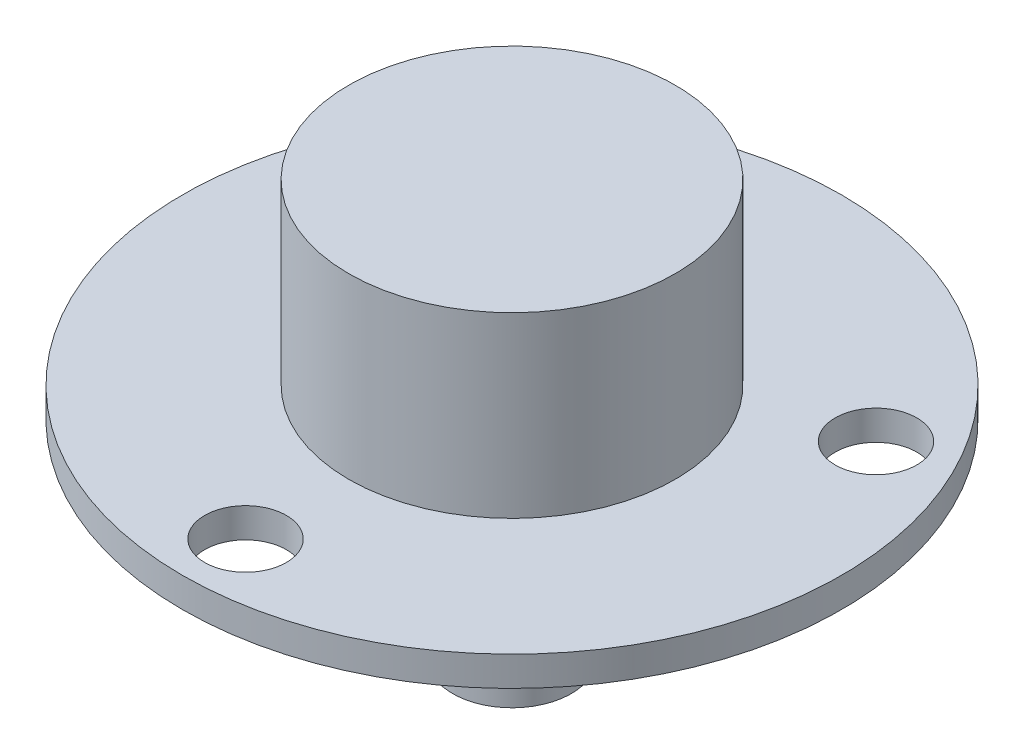
from build123d import *

# Parameters (mm, degrees)
SKETCH1_R           = 22.2
BOSS_EXTRUDE1_DEPTH = 2
SKETCH2_R           = 11
BOSS_EXTRUDE2_DEPTH = 12
BOSS_EXTRUDE3_START = -7
SKETCH2_2_R         = 11
BOSS_EXTRUDE3_DEPTH = 7
SKETCH3_R           = 4
BOSS_EXTRUDE4_DEPTH = 9
SKETCH4_R           = 2.75
CUT_EXTRUDE1_DEPTH  = 3.1


with BuildPart() as part:
    # Sketch1 → Boss-Extrude1 (new body)
    with BuildSketch(Plane(origin=(0, 0, 0), x_dir=(1, 0, 0), z_dir=(0, 1, 0))):
        Circle(SKETCH1_R)
    extrude(amount=BOSS_EXTRUDE1_DEPTH)

    # Sketch2 → Boss-Extrude2 (add)
    with BuildSketch(Plane(origin=(0, 2, 0), x_dir=(1, 0, 0), z_dir=(0, 1, 0))):
        Circle(SKETCH2_R)
    extrude(amount=BOSS_EXTRUDE2_DEPTH)

    # Sketch2_2 → Boss-Extrude3 (add)
    with BuildSketch(Plane(origin=(0, 2, 0), x_dir=(1, 0, 0), z_dir=(0, 1, 0)).offset(BOSS_EXTRUDE3_START)):
        Circle(SKETCH2_2_R)
    extrude(amount=BOSS_EXTRUDE3_DEPTH)

    # Sketch3 → Boss-Extrude4 (add)
    with BuildSketch(Plane.XZ.offset(5)):
        Circle(SKETCH3_R)
    extrude(amount=BOSS_EXTRUDE4_DEPTH)

    # Sketch4 → Cut-Extrude1 (cut)
    with BuildSketch(Plane(origin=(0, 2, 0), x_dir=(1, 0, 0), z_dir=(0, 1, 0))):
        with Locations((0, -17.95)):
            Circle(SKETCH4_R)
        with Locations((-15.545155998, 8.975)):
            Circle(SKETCH4_R)
        with Locations((15.545155998, 8.975)):
            Circle(SKETCH4_R)
    extrude(amount=-CUT_EXTRUDE1_DEPTH, mode=Mode.SUBTRACT)


solid = part.part
